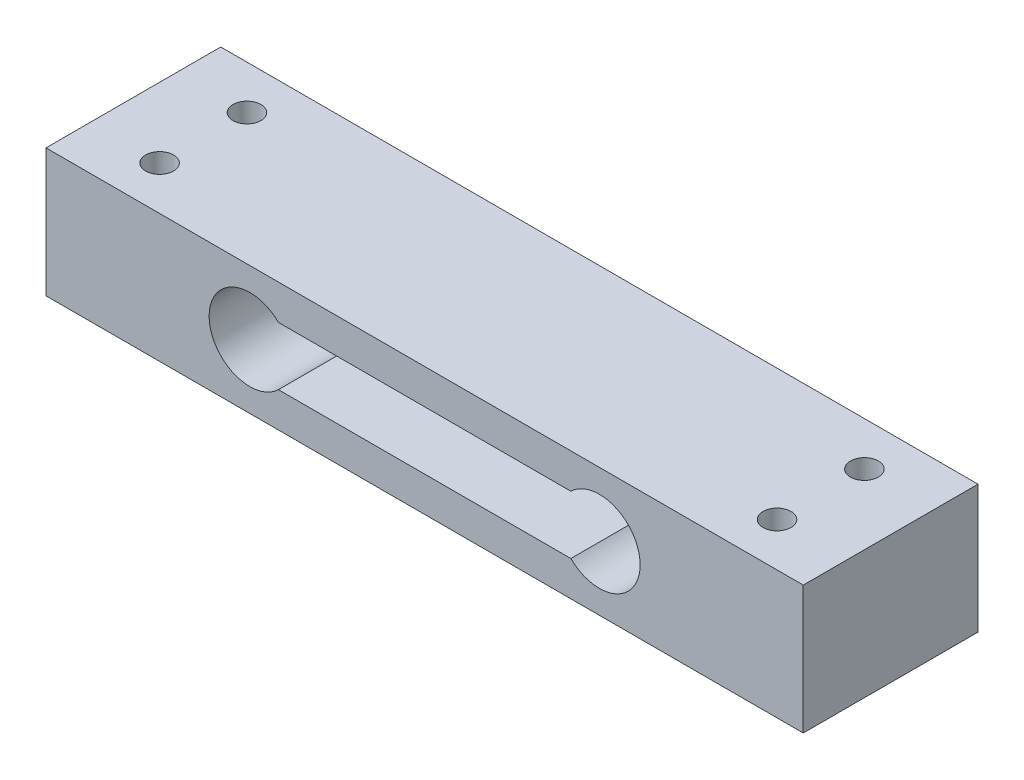
from build123d import *

# Parameters (mm, degrees)
AUFSATZ_LINEAR_AUSTRAGEN1_DEPTH      = 11
AUFSATZ_LINEAR_AUSTRAGEN1_DEPTH_BACK = 11
SKIZZE2_W                            = 130
SKIZZE2_H                            = 30
SKIZZE2_R                            = 2.4
SCHNITT_LINEAR_AUSTRAGEN1_REACH      = 74.429


with BuildPart() as part:
    # Skizze2 → Aufsatz-Linear austragen1 (new, two sides: drawn at the far end of the back side and taken through both)
    with BuildSketch(Plane(origin=(0, 0, 0), x_dir=(1, 0, 0), z_dir=(0, 1, 0)).offset(-AUFSATZ_LINEAR_AUSTRAGEN1_DEPTH_BACK)):
        Rectangle(SKIZZE2_W, SKIZZE2_H)
        with Locations((-53, -7.5)):
            Circle(SKIZZE2_R, mode=Mode.SUBTRACT)
        with Locations((-53, 7.5)):
            Circle(SKIZZE2_R, mode=Mode.SUBTRACT)
        with Locations((53, -7.5)):
            Circle(SKIZZE2_R, mode=Mode.SUBTRACT)
        with Locations((53, 7.5)):
            Circle(SKIZZE2_R, mode=Mode.SUBTRACT)
    extrude(amount=AUFSATZ_LINEAR_AUSTRAGEN1_DEPTH + AUFSATZ_LINEAR_AUSTRAGEN1_DEPTH_BACK)

    # Skizze5 → Schnitt-Linear austragen1 (cut, up to next)
    with BuildSketch(Plane.XY.offset(15), mode=Mode.PRIVATE) as schnitt_linear_austragen1_sk1:
        with BuildLine():
            Line((-25.101020514, 5), (25.101020514, 5))
            ThreePointArc((25.101020514, 5), (37, 0), (25.101020514, -5))
            Line((25.101020514, -5), (-25.101020514, -5))
            ThreePointArc((-25.101020514, -5), (-37, 0), (-25.101020514, 5))
        make_face()
    schnitt_linear_austragen1_tool1 = extrude(schnitt_linear_austragen1_sk1.sketch, amount=-SCHNITT_LINEAR_AUSTRAGEN1_REACH, mode=Mode.PRIVATE) & part.part
    add(schnitt_linear_austragen1_tool1.solids().sort_by_distance((0, 0, 15))[0], mode=Mode.SUBTRACT)


solid = part.part
